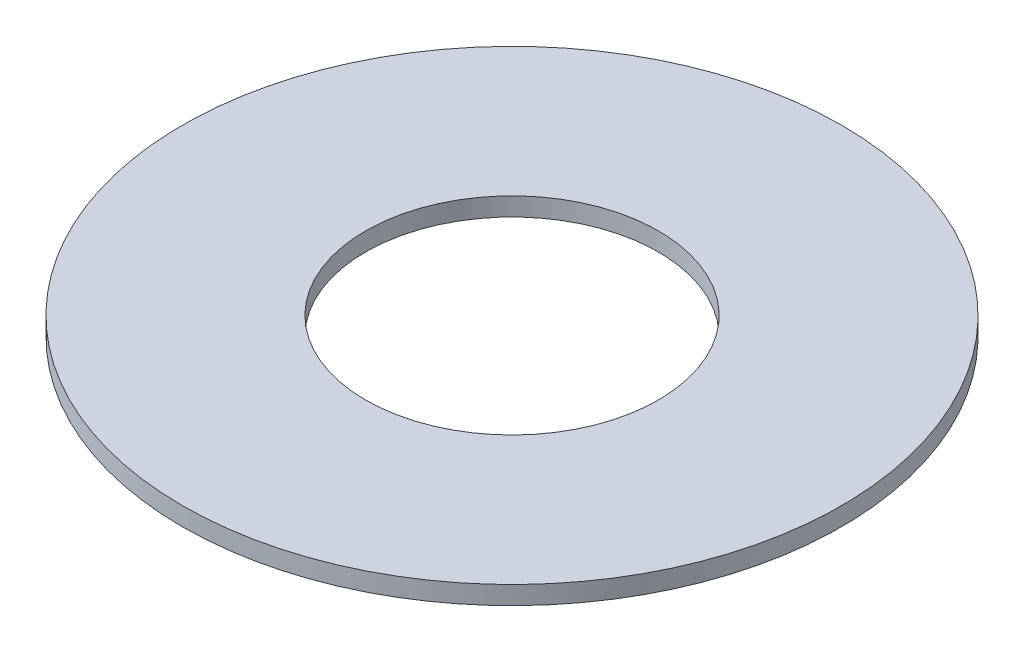
from build123d import *

# Parameters (mm, degrees)
SKETCH1_R           = 9
SKETCH1_R_2         = 4
BOSS_EXTRUDE1_DEPTH = 0.5


with BuildPart() as part:
    # Sketch1 → Boss-Extrude1 (new body)
    with BuildSketch(Plane(origin=(0, 0, 0), x_dir=(1, 0, 0), z_dir=(0, 1, 0))):
        Circle(SKETCH1_R)
        Circle(SKETCH1_R_2, mode=Mode.SUBTRACT)
    extrude(amount=BOSS_EXTRUDE1_DEPTH)


solid = part.part
